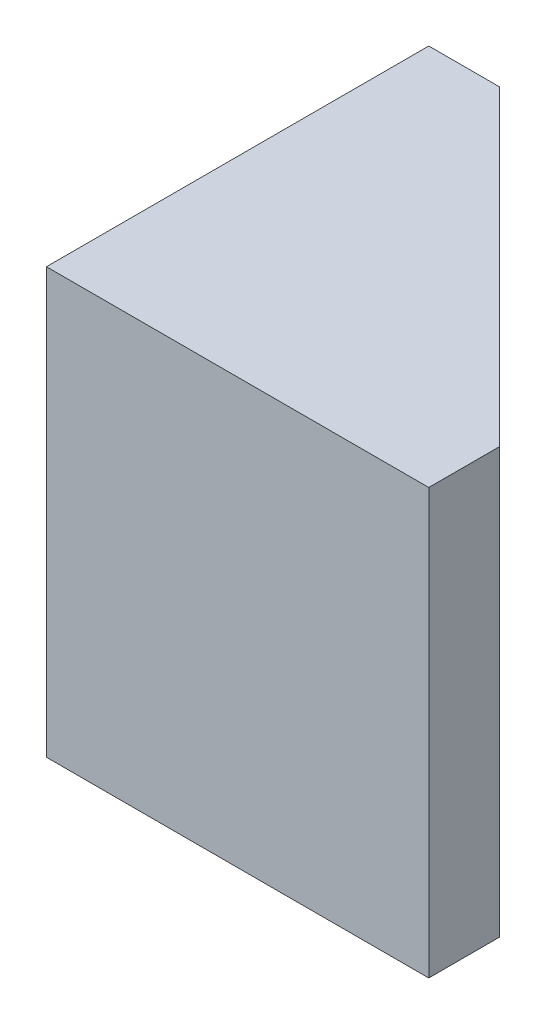
from build123d import *

# Parameters (mm, degrees)
BOSS_EXTRUDE1_DEPTH = 30
CUT_EXTRUDE1_DEPTH  = 31


with BuildPart() as part:
    # Sketch1 → Boss-Extrude1 (new body)
    with BuildSketch(Plane(origin=(0, 0, 0), x_dir=(1, 0, 0), z_dir=(0, 1, 0))):
        Polygon((0, 0), (0, 32), (32, 0), align=None)
    extrude(amount=BOSS_EXTRUDE1_DEPTH)

    # Sketch2 → Cut-Extrude1 (cut, through all)
    with BuildSketch(Plane(origin=(0, 30, 0), x_dir=(1, 0, 0), z_dir=(0, 1, 0))):
        Polygon((0, 27), (5, 27), (0, 32), align=None)
        Polygon((27, 0), (32, 0), (27, 5), align=None)
    extrude(amount=-CUT_EXTRUDE1_DEPTH, mode=Mode.SUBTRACT)


solid = part.part
